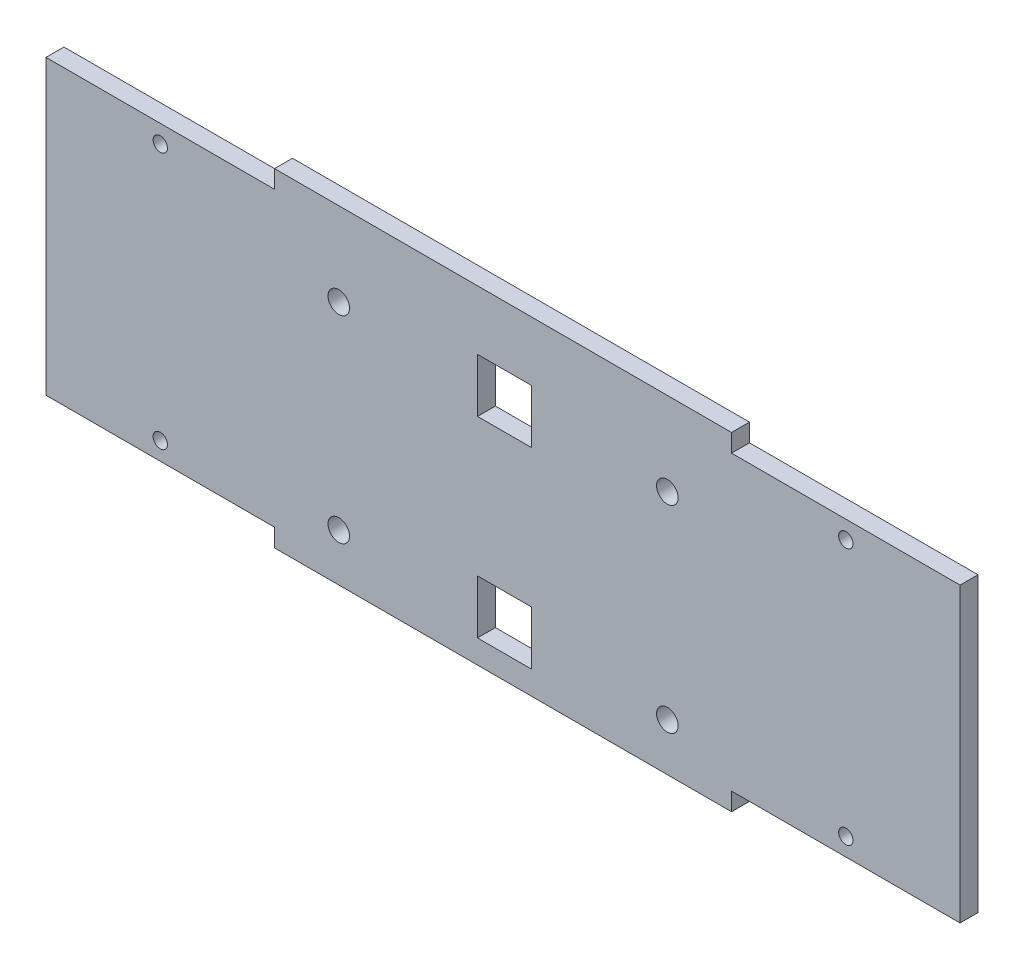
from build123d import *

# Parameters (mm, degrees)
SKETCH1_R           = 3
SKETCH1_W           = 15
SKETCH1_H           = 15
BOSS_EXTRUDE1_DEPTH = 5
SKETCH2_R           = 1.5
CUT_EXTRUDE1_DEPTH  = 185
SKETCH3_R           = 2
CUT_EXTRUDE2_DEPTH  = 10
SKETCH5_W           = 63.75
SKETCH5_H           = 5
BOSS_EXTRUDE3_DEPTH = 10
SKETCH6_W           = 127.5
SKETCH6_H           = 5
BOSS_EXTRUDE4_DEPTH = 10
SKETCH7_W           = 63.75
SKETCH7_H           = 5
BOSS_EXTRUDE5_DEPTH = 10
SKETCH8_R           = 2
BOSS_EXTRUDE6_DEPTH = 5
SKETCH8_3_R         = 2
CUT_EXTRUDE3_DEPTH  = 10


with BuildPart() as part:
    # Sketch1 → Boss-Extrude1 (new body)
    with BuildSketch(Plane.XY):
        Polygon((191.25, 71.637645579), (255, 71.637645579), (255, 0), (191.25, 0), (191.25, -5), (127.5, -5), (63.75, -5), (63.75, 0), (0, 0), (0, 71.637645579), (63.75, 71.637645579), (63.75, 76.637645579), (127.5, 76.637645579), (191.25, 76.637645579), align=None)
        with Locations((81.6684273, 63.35852795)):
            Circle(SKETCH1_R, mode=Mode.SUBTRACT)
        with Locations((173.3315727, 63.35852795)):
            Circle(SKETCH1_R, mode=Mode.SUBTRACT)
        with Locations((81.6684273, 8.27911763)):
            Circle(SKETCH1_R, mode=Mode.SUBTRACT)
        with Locations((173.3315727, 8.27911763)):
            Circle(SKETCH1_R, mode=Mode.SUBTRACT)
        with Locations((127.870410973, 62.57941032)):
            Rectangle(SKETCH1_W, SKETCH1_H, mode=Mode.SUBTRACT)
        with Locations((127.870410973, 9.058235259)):
            Rectangle(SKETCH1_W, SKETCH1_H, mode=Mode.SUBTRACT)
    extrude(amount=BOSS_EXTRUDE1_DEPTH)

    # Sketch2 → Cut-Extrude1 (cut)
    with BuildSketch(Plane(origin=(0, 0, 0), x_dir=(-1, 0, 0), z_dir=(0, 0, -1))):
        with Locations((-31.875, 5)):
            Circle(SKETCH2_R)
        with Locations((-31.875, 66.637645579)):
            Circle(SKETCH2_R)
        with Locations((-223.125, 66.637645579)):
            Circle(SKETCH2_R)
        with Locations((-223.125, 5)):
            Circle(SKETCH2_R)
    extrude(amount=-CUT_EXTRUDE1_DEPTH, mode=Mode.SUBTRACT)

    # Sketch3 → Cut-Extrude2 (cut)
    with BuildSketch(Plane(origin=(0, 0, 0), x_dir=(-1, 0, 0), z_dir=(0, 0, -1))):
        with Locations((-31.875, 5)):
            Circle(SKETCH3_R)
        with Locations((-31.875, 66.637645579)):
            Circle(SKETCH3_R)
        with Locations((-223.125, 5)):
            Circle(SKETCH3_R)
        with Locations((-223.125, 66.637645579)):
            Circle(SKETCH3_R)
    extrude(amount=-CUT_EXTRUDE2_DEPTH, mode=Mode.SUBTRACT)

    # Sketch5 → Boss-Extrude3 (add)
    with BuildSketch(Plane(origin=(0, 71.637645579, 0), x_dir=(1, 0, 0), z_dir=(0, 1, 0))):
        with Locations((223.125, -2.5)):
            Rectangle(SKETCH5_W, SKETCH5_H)
    extrude(amount=BOSS_EXTRUDE3_DEPTH)

    # Sketch6 → Boss-Extrude4 (add)
    with BuildSketch(Plane(origin=(0, 76.637645579, 0), x_dir=(1, 0, 0), z_dir=(0, 1, 0))):
        with Locations((127.5, -2.5)):
            Rectangle(SKETCH6_W, SKETCH6_H)
    extrude(amount=BOSS_EXTRUDE4_DEPTH)

    # Sketch7 → Boss-Extrude5 (add)
    with BuildSketch(Plane(origin=(0, 71.637645579, 0), x_dir=(1, 0, 0), z_dir=(0, 1, 0))):
        with Locations((31.875, -2.5)):
            Rectangle(SKETCH7_W, SKETCH7_H)
    extrude(amount=BOSS_EXTRUDE5_DEPTH)

    # Sketch8 → Boss-Extrude6 (add)
    with BuildSketch(Plane(origin=(0, 0, 0), x_dir=(-1, 0, 0), z_dir=(0, 0, -1))):
        with Locations((-31.875, 66.637645579)):
            Circle(SKETCH8_R)
        with Locations((-31.875, 76.637645579)):
            Circle(SKETCH8_R)
        with Locations((-223.125, 76.637645579)):
            Circle(SKETCH8_R)
        with Locations((-223.125, 66.637645579)):
            Circle(SKETCH8_R)
    extrude(amount=-BOSS_EXTRUDE6_DEPTH)

    # Sketch8_3 → Cut-Extrude3 (cut)
    with BuildSketch(Plane(origin=(0, 0, 0), x_dir=(-1, 0, 0), z_dir=(0, 0, -1))):
        with Locations((-31.875, 76.637645579)):
            Circle(SKETCH8_3_R)
        with Locations((-223.125, 76.637645579)):
            Circle(SKETCH8_3_R)
    extrude(amount=-CUT_EXTRUDE3_DEPTH, mode=Mode.SUBTRACT)


solid = part.part
